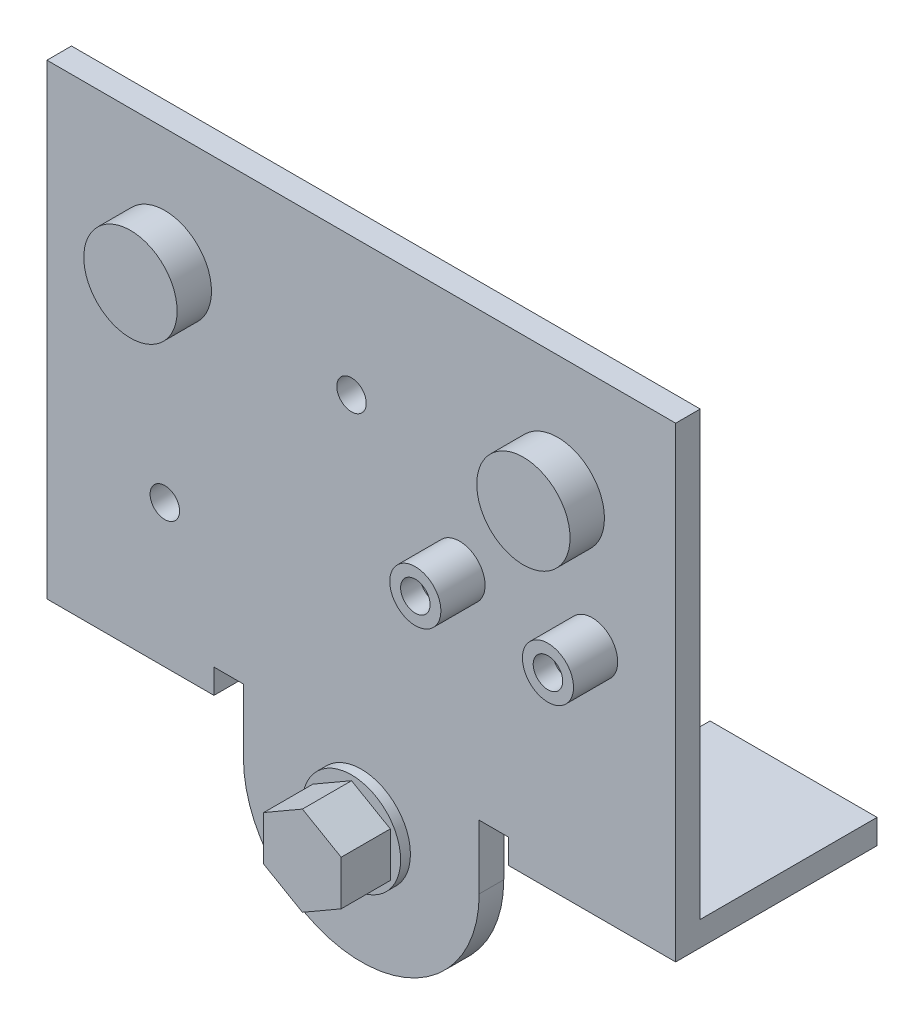
from build123d import *

# Parameters (mm, degrees)
SKETCH1_W           = 64
SKETCH1_H           = 45
BOSS_EXTRUDE1_DEPTH = 2.5
SKETCH3_W           = 17
SKETCH3_H           = 20.5
BOSS_EXTRUDE2_DEPTH = 2.5
BOSS_EXTRUDE4_DEPTH = 2.5
SKETCH6_R           = 5
BOSS_EXTRUDE5_DEPTH = 1
BOSS_EXTRUDE6_DEPTH = 5
SKETCH8_R           = 1.5
CUT_EXTRUDE1_DEPTH  = 2.5
SKETCH9_R           = 4.75
BOSS_EXTRUDE7_DEPTH = 3.5
SKETCH10_R          = 2.6
BOSS_EXTRUDE8_DEPTH = 4.5
SKETCH11_R          = 1.5
CUT_EXTRUDE2_DEPTH  = 2
SKETCH12_R          = 1.5
CUT_EXTRUDE3_DEPTH  = 2


with BuildPart() as part:
    # Sketch1 → Boss-Extrude1 (new body)
    with BuildSketch(Plane.XY):
        with Locations((0, -2.648063781)):
            Rectangle(SKETCH1_W, SKETCH1_H)
    extrude(amount=BOSS_EXTRUDE1_DEPTH)

    # Sketch3 → Boss-Extrude2 (add)
    with BuildSketch(Plane.XZ.offset(25.148063781)):
        with Locations((-23.5, -7.75)):
            Rectangle(SKETCH3_W, SKETCH3_H)
        with Locations((23.5, -7.75)):
            Rectangle(SKETCH3_W, SKETCH3_H)
    extrude(amount=BOSS_EXTRUDE2_DEPTH)

    # Sketch5 → Boss-Extrude4 (add)
    with BuildSketch(Plane.XY.offset(2.5)):
        with BuildLine():
            Line((-12, -25.148063781), (-12, -31.648063781))
            ThreePointArc((-12, -31.648063781), (0, -43.648063781), (12, -31.648063781))
            Line((12, -31.648063781), (12, -25.148063781))
            Line((12, -25.148063781), (-12, -25.148063781))
        make_face()
    extrude(amount=-BOSS_EXTRUDE4_DEPTH)

    # Sketch6 → Boss-Extrude5 (add)
    with BuildSketch(Plane.XY.offset(2.5)):
        with Locations((0, -31.648063781)):
            Circle(SKETCH6_R)
    extrude(amount=BOSS_EXTRUDE5_DEPTH)

    # Sketch7 → Boss-Extrude6 (add)
    with BuildSketch(Plane.XY.offset(3.5)):
        Polygon((0.007672283, -27.164333449), (-3.933372225, -29.439696556), (-3.933372225, -33.990422772), (0.007672283, -36.26578588), (3.948716792, -33.990422772), (3.948716792, -29.439696556), align=None)
    extrude(amount=BOSS_EXTRUDE6_DEPTH)

    # Sketch8 → Cut-Extrude1 (cut)
    with BuildSketch(Plane.XY.offset(2.5)):
        with Locations((-20, -13.148063781)):
            Circle(SKETCH8_R)
        with Locations((-1, 5.851936219)):
            Circle(SKETCH8_R)
    extrude(amount=-CUT_EXTRUDE1_DEPTH, mode=Mode.SUBTRACT)

    # Sketch9 → Boss-Extrude7 (add)
    with BuildSketch(Plane.XY.offset(2.5)):
        with Locations((-20, 7.851936219)):
            Circle(SKETCH9_R)
        with Locations((20, 7.851936219)):
            Circle(SKETCH9_R)
    extrude(amount=BOSS_EXTRUDE7_DEPTH)

    # Sketch10 → Boss-Extrude8 (add)
    with BuildSketch(Plane.XY.offset(2.5)):
        with Locations((10, -4.148063781)):
            Circle(SKETCH10_R)
        with Locations((23.5, -4.148063781)):
            Circle(SKETCH10_R)
    extrude(amount=BOSS_EXTRUDE8_DEPTH)

    # Sketch11 → Cut-Extrude2 (cut)
    with BuildSketch(Plane.XY.offset(7)):
        with Locations((10, -4.148063781)):
            Circle(SKETCH11_R)
    extrude(amount=-CUT_EXTRUDE2_DEPTH, mode=Mode.SUBTRACT)

    # Sketch12 → Cut-Extrude3 (cut)
    with BuildSketch(Plane.XY.offset(7)):
        with Locations((23.5, -4.148063781)):
            Circle(SKETCH12_R)
    extrude(amount=-CUT_EXTRUDE3_DEPTH, mode=Mode.SUBTRACT)


solid = part.part
